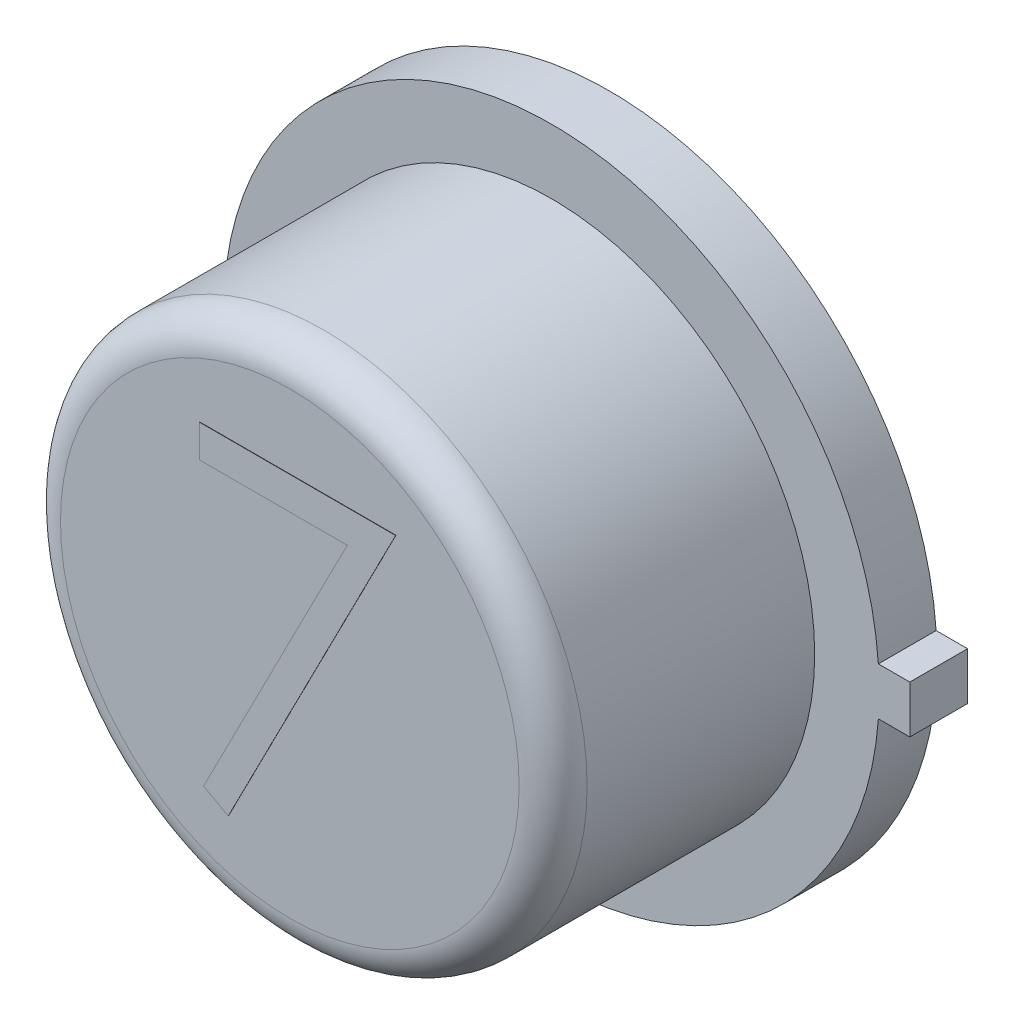
from build123d import *

# Parameters (mm, degrees)
BOSS_EXTRUDE1_DEPTH = 0.4318
SKETCH2_R           = 1.9685
BOSS_EXTRUDE2_DEPTH = 1.9558
SKETCH3_R           = 1.757566481
BOSS_EXTRUDE3_DEPTH = 0.00254
FILLET1_R           = 0.254
BOSS_EXTRUDE6_DEPTH = 0.00254


with BuildPart() as part:
    # Sketch1 → Boss-Extrude1 (new body)
    with BuildSketch(Plane.XY):
        with BuildLine():
            Line((2.6797, 0.1778), (2.4511, 0.1778))
            Line((2.4511, 0.1778), (2.44464279, 0.1778))
            ThreePointArc((2.44464279, 0.1778), (-2.4511, 0), (2.44464279, -0.1778))
            Line((2.44464279, -0.1778), (2.4511, -0.1778))
            Line((2.4511, -0.1778), (2.6797, -0.1778))
            Line((2.6797, -0.1778), (2.6797, 0.1778))
        make_face()
    extrude(amount=BOSS_EXTRUDE1_DEPTH)

    # Sketch2 → Boss-Extrude2 (add)
    with BuildSketch(Plane.XY.offset(0.4318)):
        Circle(SKETCH2_R)
    extrude(amount=BOSS_EXTRUDE2_DEPTH)

    # Sketch3 → Boss-Extrude3 (add)
    with BuildSketch(Plane(origin=(0, 0, 0), x_dir=(-1, 0, 0), z_dir=(0, 0, -1))):
        Circle(SKETCH3_R)
    extrude(amount=BOSS_EXTRUDE3_DEPTH)

    # Fillet1
    fillet1_edges = [part.edges().sort_by_distance(p)[0] for p in [
        (-1.9685, 0, 2.3876),
    ]]
    fillet(fillet1_edges, radius=FILLET1_R)

    # Sketch4 → Boss-Extrude6 (add)
    with BuildSketch(Plane.XY.offset(2.3876)):
        Polygon((-0.671634615, 1.163108793), (0.79375, 1.163108793), (-0.457932692, -1.279198899), (-0.642536809, -1.177595083), (0.432173978, 0.918878024), (-0.671634615, 0.918878024), align=None)
    extrude(amount=BOSS_EXTRUDE6_DEPTH)


solid = part.part
